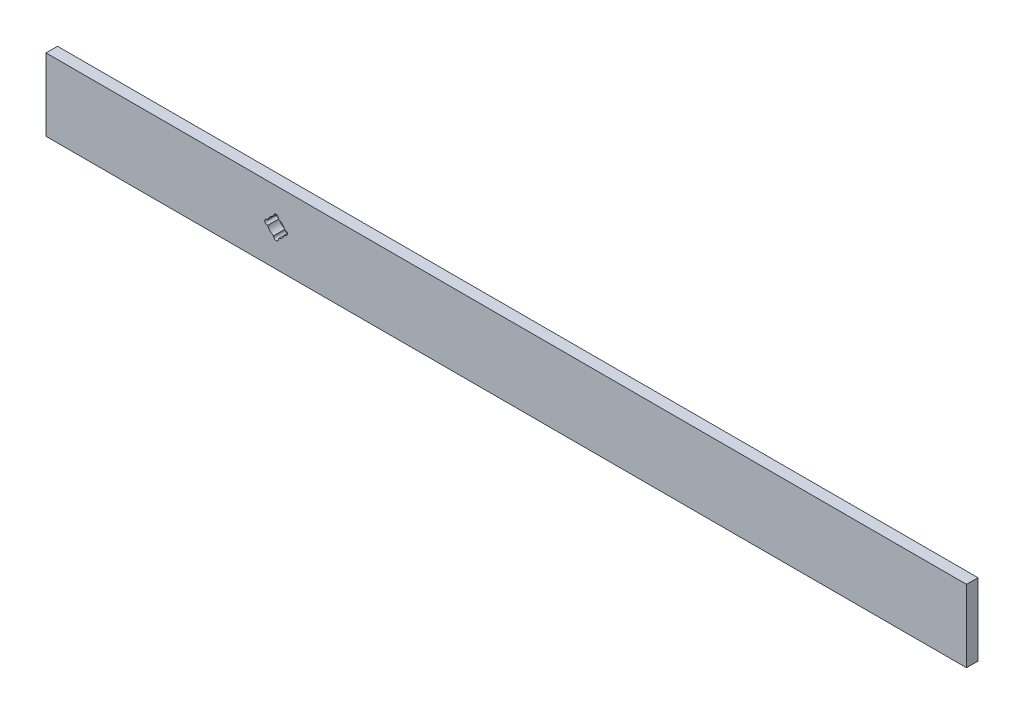
from build123d import *

# Parameters (mm, degrees)
SKETCH1_W           = 508
SKETCH1_H           = 39.878
BOSS_EXTRUDE1_DEPTH = 6.35
CUT_EXTRUDE3_DEPTH  = 7.35


with BuildPart() as part:
    # Sketch1 → Boss-Extrude1 (new body)
    with BuildSketch(Plane.XY):
        with Locations((254, 19.939)):
            Rectangle(SKETCH1_W, SKETCH1_H)
    extrude(amount=BOSS_EXTRUDE1_DEPTH)

    # Sketch2 → Cut-Extrude3 (cut, through all)
    with BuildSketch(Plane.XY.offset(6.35)):
        with BuildLine():
            ThreePointArc((128.3462, 24.892), (127, 26.2382), (125.6538, 24.892))
            Line((125.6538, 24.892), (125.6538, 24.546982847))
            ThreePointArc((125.6538, 24.546982847), (123.605463186, 23.333536814), (122.392017153, 21.2852))
            Line((122.392017153, 21.2852), (122.047, 21.2852))
            ThreePointArc((122.047, 21.2852), (120.7008, 19.939), (122.047, 18.5928))
            Line((122.047, 18.5928), (122.392017153, 18.5928))
            ThreePointArc((122.392017153, 18.5928), (123.605463186, 16.544463186), (125.6538, 15.331017153))
            Line((125.6538, 15.331017153), (125.6538, 14.986))
            ThreePointArc((125.6538, 14.986), (127, 13.6398), (128.3462, 14.986))
            Line((128.3462, 14.986), (128.3462, 15.331017153))
            ThreePointArc((128.3462, 15.331017153), (130.394536814, 16.544463186), (131.607982847, 18.5928))
            Line((131.607982847, 18.5928), (131.953, 18.5928))
            ThreePointArc((131.953, 18.5928), (133.2992, 19.939), (131.953, 21.2852))
            Line((131.953, 21.2852), (131.607982847, 21.2852))
            ThreePointArc((131.607982847, 21.2852), (130.394536814, 23.333536814), (128.3462, 24.546982847))
            Line((128.3462, 24.546982847), (128.3462, 24.892))
        make_face()
    extrude(amount=-CUT_EXTRUDE3_DEPTH, mode=Mode.SUBTRACT)


solid = part.part
